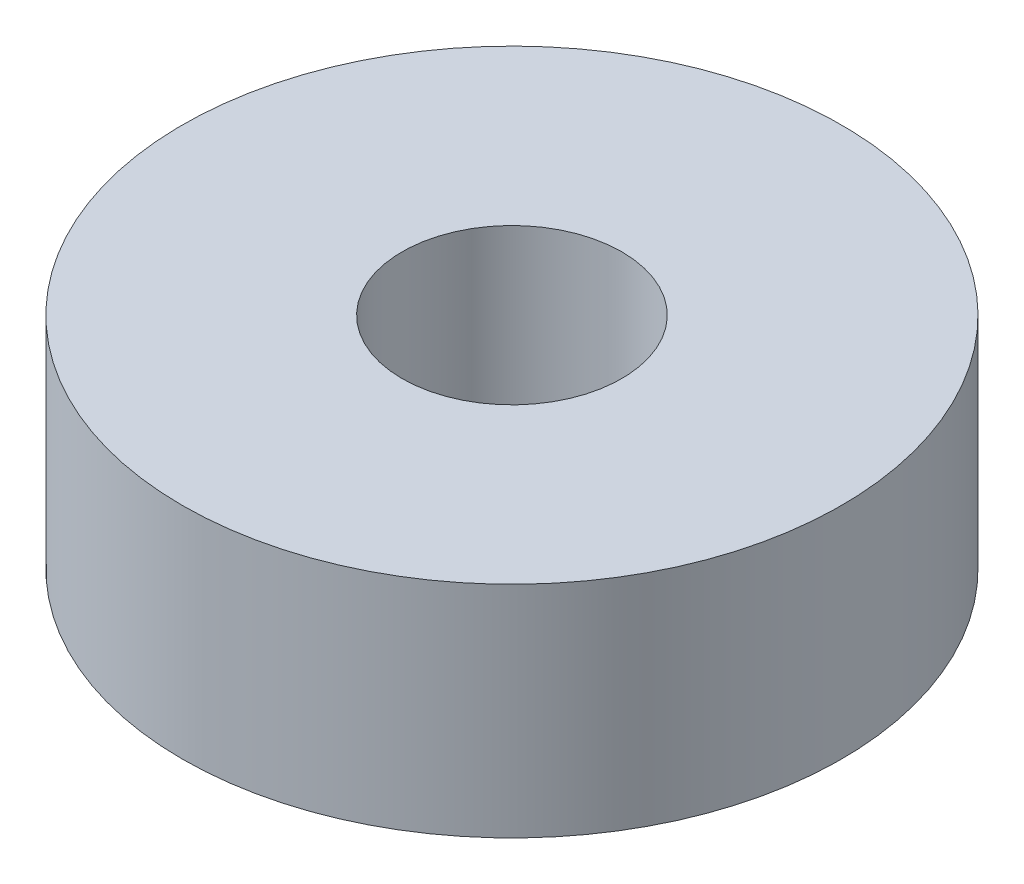
from build123d import *

# Parameters (mm, degrees)
SKETCH1_R           = 6
SKETCH1_R_2         = 2
BOSS_EXTRUDE1_DEPTH = 4


with BuildPart() as part:
    # Sketch1 → Boss-Extrude1 (new body)
    with BuildSketch(Plane(origin=(0, 0, 0), x_dir=(1, 0, 0), z_dir=(0, 1, 0))):
        Circle(SKETCH1_R)
        Circle(SKETCH1_R_2, mode=Mode.SUBTRACT)
    extrude(amount=BOSS_EXTRUDE1_DEPTH)


solid = part.part
